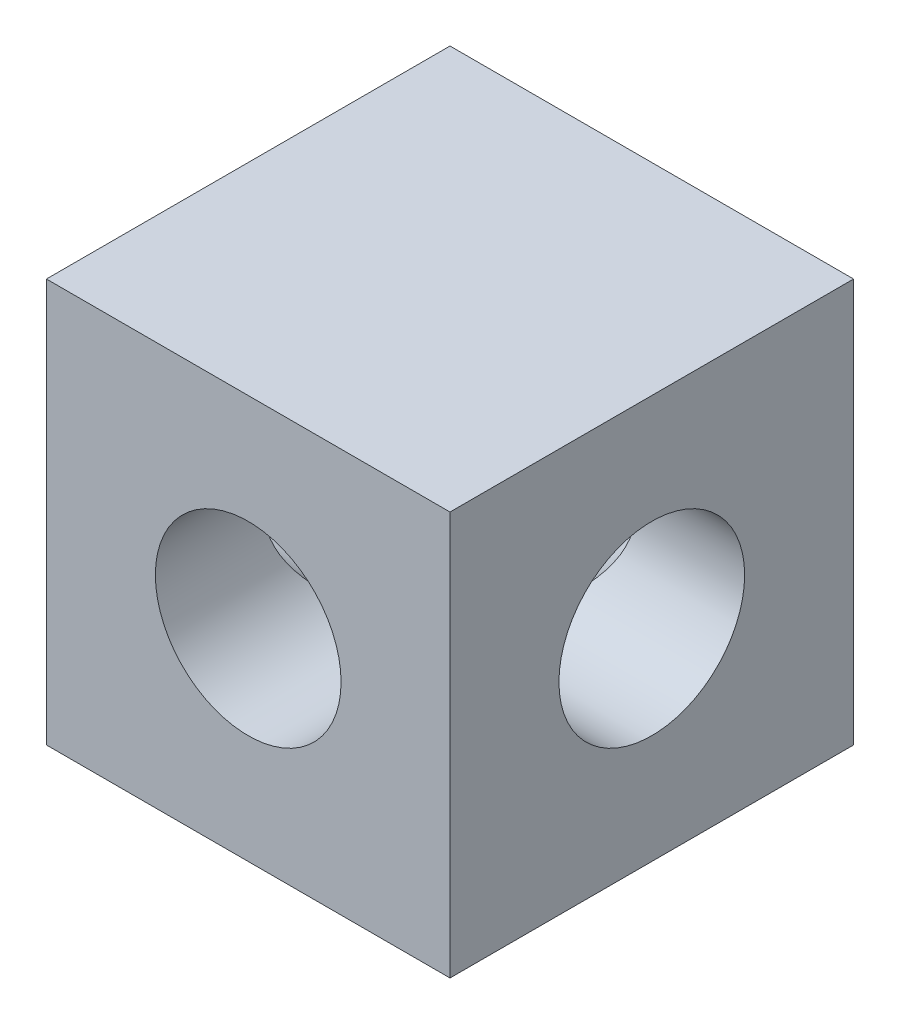
from build123d import *

# Parameters (mm, degrees)
SKETCH1_W           = 20.32
SKETCH1_H           = 20.32
BOSS_EXTRUDE1_DEPTH = 20.32
SKETCH2_R           = 4.675
CUT_EXTRUDE1_DEPTH  = 10.1
CIRPATTERN1_COUNT   = 4


with BuildPart() as part:
    # Sketch1 → Boss-Extrude1 (new body)
    with BuildSketch(Plane(origin=(0, 0, 0), x_dir=(1, 0, 0), z_dir=(0, 1, 0))):
        Rectangle(SKETCH1_W, SKETCH1_H)
    extrude(amount=BOSS_EXTRUDE1_DEPTH)

    # Sketch2 → Cut-Extrude1 (cut)
    with BuildSketch(Plane.XY.offset(10.16)):
        with Locations((0, 10.16)):
            Circle(SKETCH2_R)
    cut_extrude1 = extrude(amount=-CUT_EXTRUDE1_DEPTH, mode=Mode.SUBTRACT)

    # CirPattern1: Cut-Extrude1 ×4 about axis
    cirpattern1_axis = Axis((0, 0, 0), (0, 1, 0))
    for i in range(1, CIRPATTERN1_COUNT):
        add(cut_extrude1.rotate(cirpattern1_axis, i * 360 / CIRPATTERN1_COUNT), mode=Mode.SUBTRACT)


solid = part.part
